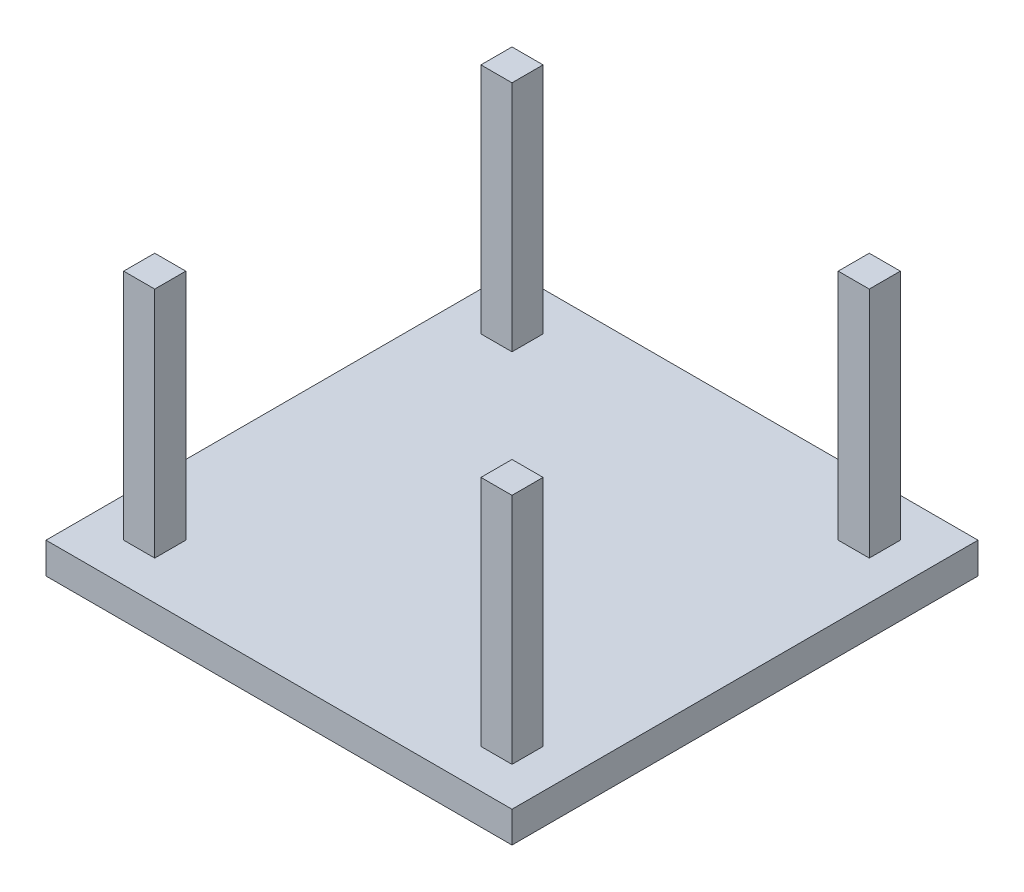
from build123d import *

# Parameters (mm, degrees)
SKETCH1_W           = 30
SKETCH1_H           = 30
BOSS_EXTRUDE1_DEPTH = 2
SKETCH2_W           = 2
SKETCH2_H           = 2
BOSS_EXTRUDE2_DEPTH = 15


with BuildPart() as part:
    # Sketch1 → Boss-Extrude1 (new body)
    with BuildSketch(Plane(origin=(0, 0, 0), x_dir=(1, 0, 0), z_dir=(0, 1, 0))):
        with Locations((-15, 15)):
            Rectangle(SKETCH1_W, SKETCH1_H)
    extrude(amount=BOSS_EXTRUDE1_DEPTH)

    # Sketch2 → Boss-Extrude2 (add)
    with BuildSketch(Plane(origin=(0, 2, 0), x_dir=(1, 0, 0), z_dir=(0, 1, 0))):
        with Locations((-26.5, 26.5)):
            Rectangle(SKETCH2_W, SKETCH2_H)
        with Locations((-3.5, 26.5)):
            Rectangle(SKETCH2_W, SKETCH2_H)
        with Locations((-3.5, 3.5)):
            Rectangle(SKETCH2_W, SKETCH2_H)
        with Locations((-26.5, 3.5)):
            Rectangle(SKETCH2_W, SKETCH2_H)
    extrude(amount=BOSS_EXTRUDE2_DEPTH)


solid = part.part
